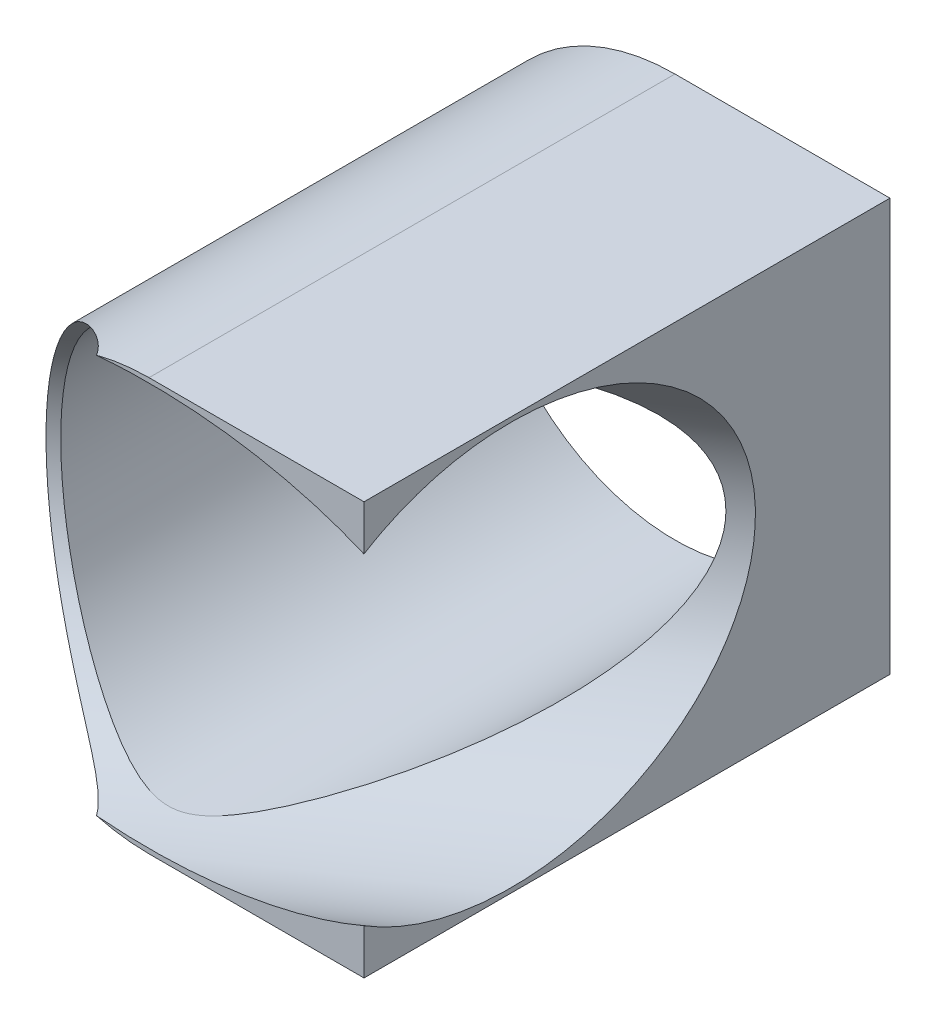
from build123d import *

# Parameters (mm, degrees)
SKETCH1_R           = 23.525
SKETCH1_R_2         = 22.525
BOSS_EXTRUDE1_DEPTH = 60
BOSS_EXTRUDE2_DEPTH = 60
SKETCH2_R           = 23
CUT_EXTRUDE1_DEPTH  = 112.626209254


with BuildPart() as part:
    # Sketch1 → Boss-Extrude1 (new body)
    with BuildSketch(Plane.XY):
        with Locations((443.127496957, 0)):
            Circle(SKETCH1_R)
        with Locations((443.127496957, 0)):
            Circle(SKETCH1_R_2, mode=Mode.SUBTRACT)
    extrude(amount=-BOSS_EXTRUDE1_DEPTH)

    # Sketch3 → Boss-Extrude2 (add)
    with BuildSketch(Plane(origin=(0, 0, -60), x_dir=(-1, 0, 0), z_dir=(0, 0, -1))):
        with BuildLine():
            Line((-466.652496957, -23.525), (-443.127496957, -23.525))
            ThreePointArc((-443.127496957, -23.525), (-459.762183984, -16.634687027), (-466.652496957, 0))
            Line((-466.652496957, 0), (-466.652496957, -23.525))
        make_face()
        Polygon((-466.652496957, 23.525), (-467.652496957, 23.525), (-467.652496957, -23.525), (-466.652496957, -23.525), (-466.652496957, 0), align=None)
        with BuildLine():
            Line((-466.652496957, 23.525), (-466.652496957, 0))
            ThreePointArc((-466.652496957, 0), (-459.762183984, 16.634687027), (-443.127496957, 23.525))
            Line((-443.127496957, 23.525), (-466.652496957, 23.525))
        make_face()
    extrude(amount=-BOSS_EXTRUDE2_DEPTH)

    # Sketch2 → Cut-Extrude1 (cut, through all)
    with BuildSketch(Plane(origin=(254.325020267, 0, -174.059113982), x_dir=(0.564788358, 0, 0.825235791), z_dir=(-0.825235791, 0, 0.564788358))):
        with Locations((250.273251396, 0)):
            Circle(SKETCH2_R)
    extrude(amount=-CUT_EXTRUDE1_DEPTH, mode=Mode.SUBTRACT)


solid = part.part
